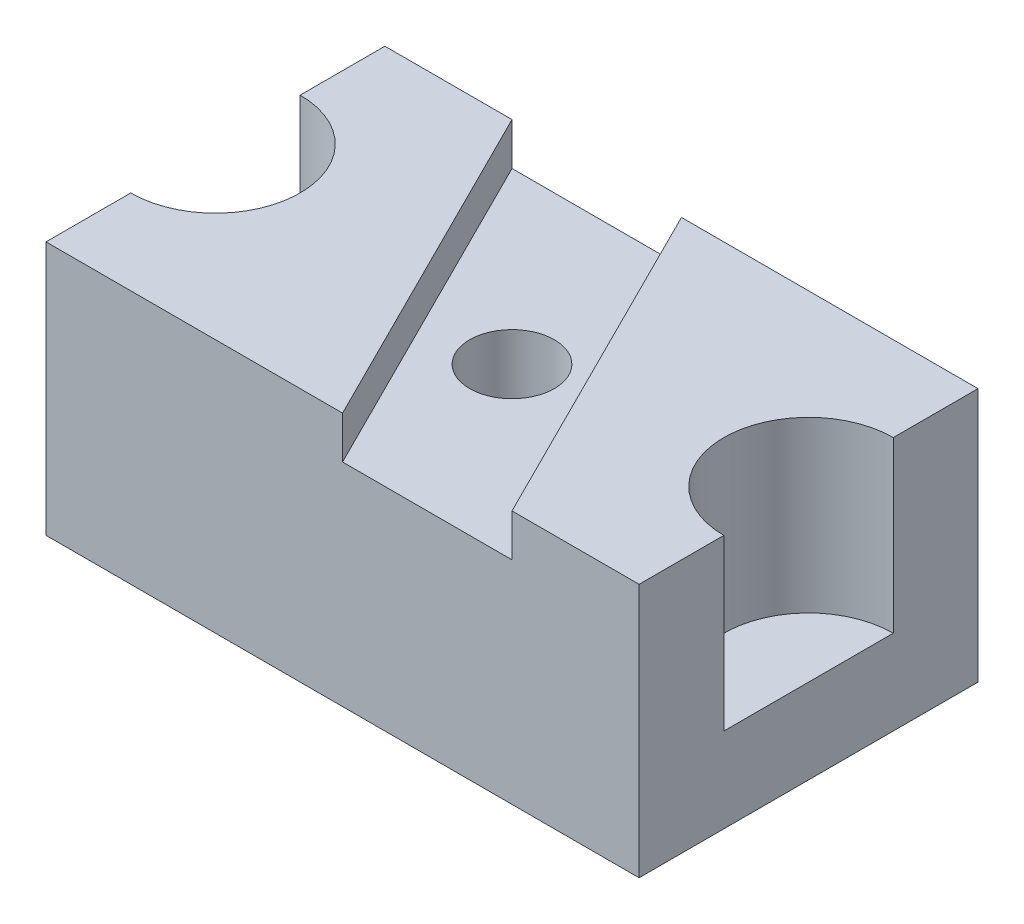
from build123d import *

# Parameters (mm, degrees)
BOSS_EXTRUDE1_DEPTH   = 1
BOSS_EXTRUDE1_2_DEPTH = 1
BOSS_EXTRUDE2_DEPTH   = 3
SKETCH1_4_R           = 0.5
BOSS_EXTRUDE3_DEPTH   = 2.5


with BuildPart() as part:
    # Sketch1 → Boss-Extrude1 (new body)
    with BuildSketch(Plane(origin=(0, 0, 0), x_dir=(1, 0, 0), z_dir=(0, 1, 0))):
        with BuildLine():
            Line((-3.5, 1), (-3.5, -1))
            ThreePointArc((-3.5, -1), (-2.5, 0), (-3.5, 1))
        make_face()
    extrude(amount=BOSS_EXTRUDE1_DEPTH)



with BuildPart() as body_2:
    # Sketch1 → Boss-Extrude1 2 (new body)
    with BuildSketch(Plane(origin=(0, 0, 0), x_dir=(1, 0, 0), z_dir=(0, 1, 0))):
        with BuildLine():
            ThreePointArc((3.5, 1), (2.5, 0), (3.5, -1))
            Line((3.5, -1), (3.5, 1))
        make_face()
    extrude(amount=BOSS_EXTRUDE1_2_DEPTH)


with BuildPart() as part_1:
    add(part.part)

    add(body_2.part)  # Boss-Extrude2 merges body 2
    # Sketch1_3 → Boss-Extrude2 (add)
    with BuildSketch(Plane(origin=(0, 0, 0), x_dir=(1, 0, 0), z_dir=(0, 1, 0))):
        with BuildLine():
            Line((-3.5, -2), (0, -2))
            Line((0, -2), (-2, 2))
            Line((-2, 2), (-3.5, 2))
            Line((-3.5, 2), (-3.5, 1))
            ThreePointArc((-3.5, 1), (-2.5, 0), (-3.5, -1))
            Line((-3.5, -1), (-3.5, -2))
        make_face()
        with BuildLine():
            Line((0, 2), (2, -2))
            Line((2, -2), (3.5, -2))
            Line((3.5, -2), (3.5, -1))
            ThreePointArc((3.5, -1), (2.5, 0), (3.5, 1))
            Line((3.5, 1), (3.5, 2))
            Line((3.5, 2), (0, 2))
        make_face()
    extrude(amount=BOSS_EXTRUDE2_DEPTH)

    # Sketch1_4 → Boss-Extrude3 (add)
    with BuildSketch(Plane(origin=(0, 0, 0), x_dir=(1, 0, 0), z_dir=(0, 1, 0))):
        Polygon((-2, 2), (0, -2), (2, -2), (0, 2), align=None)
        Circle(SKETCH1_4_R, mode=Mode.SUBTRACT)
    extrude(amount=BOSS_EXTRUDE3_DEPTH)


solid = part_1.part
